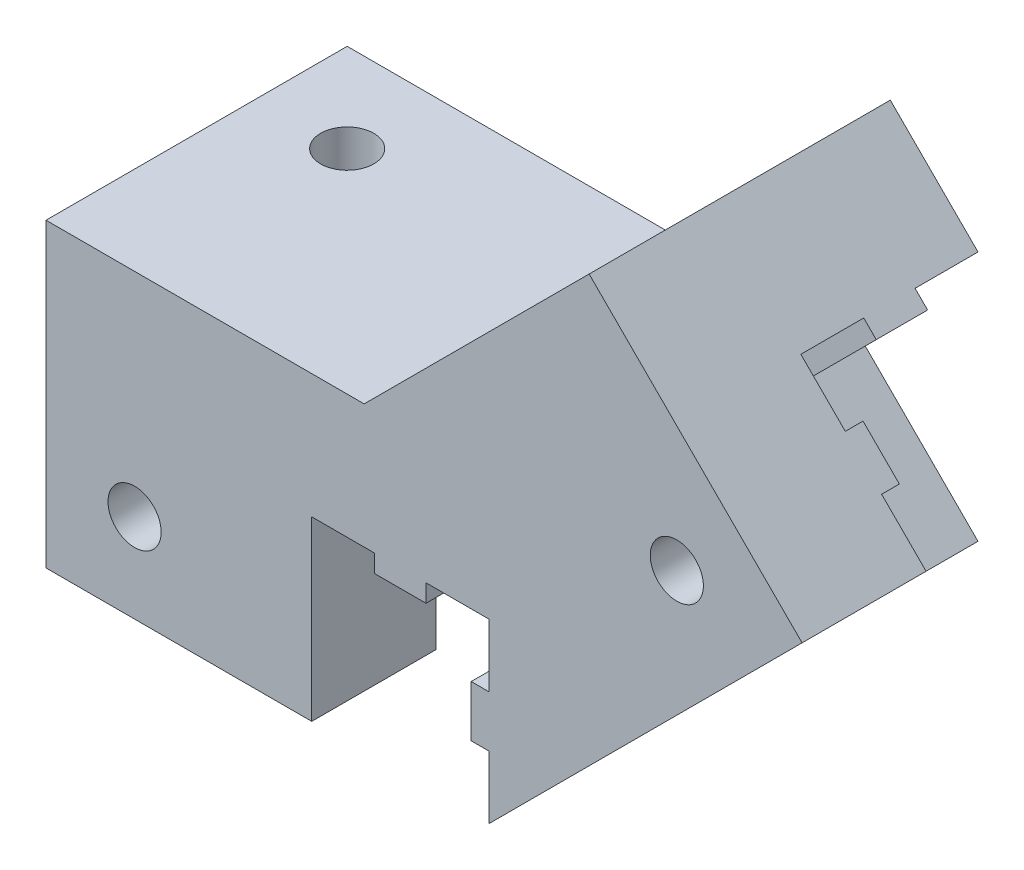
from build123d import *

# Parameters (mm, degrees)
MAIN_DEPTH          = 17
CUT_EXTRUDE1_DEPTH  = 10
SKETCH3_R           = 1.5
CUT_EXTRUDE2_DEPTH  = 18
SKETCH4_W           = 2.9
SKETCH4_H           = 1
SKETCH4_W_2         = 1
SKETCH4_H_2         = 2.9
BOSS_EXTRUDE1_DEPTH = 7
SKETCH5_W           = 15
SKETCH5_H           = 2.9
BOSS_EXTRUDE2_DEPTH = 1
SKETCH6_R           = 1.5
CUT_EXTRUDE3_DEPTH  = 18
BOSS_EXTRUDE3_DEPTH = 15
SKETCH8_R           = 1.5
CUT_EXTRUDE4_DEPTH  = 18
SKETCH9_R           = 1.5
CUT_EXTRUDE5_DEPTH  = 18.67766953


with BuildPart() as part:
    # Sketch1 → Main (new body)
    with BuildSketch(Plane.XY):
        Polygon((-90, -90), (-72.32233047, -72.32233047), (-84.343145751, -60.30151519), (-97.04163056, -73), (-115, -73), (-115, -80), (-90, -80), align=None)
    extrude(amount=MAIN_DEPTH)

    # Sketch2 → Cut-Extrude1 (cut)
    with BuildSketch(Plane(origin=(-72.32233047, -72.32233047, 0), x_dir=(0.707106781, -0.707106781, 0), z_dir=(0.707106781, 0.707106781, 0))):
        Polygon((-3.55, -10), (0, -10), (0, 0), (-10, 0), (-10, -3.55), (-9, -3.55), (-9, -6.45), (-10, -6.45), (-10, -10), (-6.45, -10), (-6.45, -9), (-3.55, -9), align=None)
    extrude(amount=-CUT_EXTRUDE1_DEPTH, mode=Mode.SUBTRACT)

    # Sketch3 → Cut-Extrude2 (cut, through all)
    with BuildSketch(Plane.XY.offset(17)):
        with Locations((-79.393398282, -72.32233047)):
            Circle(SKETCH3_R)
    extrude(amount=-CUT_EXTRUDE2_DEPTH, mode=Mode.SUBTRACT)

    # Sketch4 → Boss-Extrude1 (add)
    with BuildSketch(Plane.XY.offset(10)):
        with Locations((-95, -80.5)):
            Rectangle(SKETCH4_W, SKETCH4_H)
        with Locations((-90.5, -85)):
            Rectangle(SKETCH4_W_2, SKETCH4_H_2)
    extrude(amount=BOSS_EXTRUDE1_DEPTH)

    # Sketch5 → Boss-Extrude2 (add)
    with BuildSketch(Plane.XZ.offset(80)):
        with Locations((-107.5, 5)):
            Rectangle(SKETCH5_W, SKETCH5_H)
    extrude(amount=BOSS_EXTRUDE2_DEPTH)

    # Sketch6 → Cut-Extrude3 (cut, through all)
    with BuildSketch(Plane(origin=(0, -73, 0), x_dir=(1, 0, 0), z_dir=(0, 1, 0))):
        with Locations((-110, -5)):
            Circle(SKETCH6_R)
    extrude(amount=-CUT_EXTRUDE3_DEPTH, mode=Mode.SUBTRACT)

    # Sketch7 → Boss-Extrude3 (add)
    with BuildSketch(Plane.ZY.offset(115)):
        Polygon((17, -80), (17, -90), (10, -90), (10, -86.45), (9, -86.45), (9, -83.55), (10, -83.55), (10, -80), align=None)
    extrude(amount=-BOSS_EXTRUDE3_DEPTH)

    # Sketch8 → Cut-Extrude4 (cut, through all)
    with BuildSketch(Plane.XY.offset(17)):
        with Locations((-110, -85)):
            Circle(SKETCH8_R)
    extrude(amount=-CUT_EXTRUDE4_DEPTH, mode=Mode.SUBTRACT)

    # Sketch9 → Cut-Extrude5 (cut, through all)
    with BuildSketch(Plane.ZY.offset(90)):
        with Locations((5, -85)):
            Circle(SKETCH9_R)
    extrude(amount=-CUT_EXTRUDE5_DEPTH, mode=Mode.SUBTRACT)


solid = part.part
